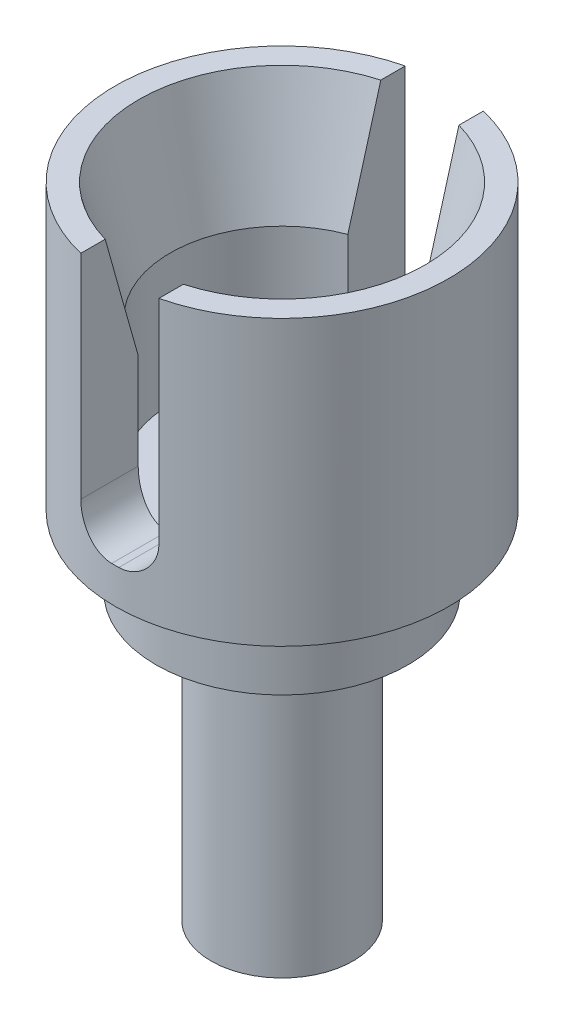
from build123d import *

# Parameters (mm, degrees)
SKETCH1_R               = 2
BOSS_EXTRUDE1_DEPTH     = 8
SKETCH1_3_R             = 3.55
BOSS_EXTRUDE2_DEPTH     = 2
SKETCH2_R               = 4.7
BOSS_EXTRUDE3_DEPTH     = 8
CUT_EXTRUDE1_DEPTH      = 20.188017094
CUT_EXTRUDE1_DEPTH_BACK = 7
SKETCH3_R               = 3.15
CHAMFER1_SIZE           = 3.3
CHAMFER1_SIZE2          = 0.884232335
CUT_EXTRUDE2_DEPTH      = 13.007497658
CUT_EXTRUDE2_DEPTH_BACK = 13.007497658
SKETCH4_W               = 2.2
SKETCH4_H               = 7
FILLET1_R               = 1


with BuildPart() as part:
    # Sketch1 → Boss-Extrude1 (new body)
    with BuildSketch(Plane(origin=(0, 0, 0), x_dir=(1, 0, 0), z_dir=(0, 1, 0))):
        Circle(SKETCH1_R)
    extrude(amount=-BOSS_EXTRUDE1_DEPTH)

    # Sketch1_3 → Boss-Extrude2 (add)
    with BuildSketch(Plane(origin=(0, 0, 0), x_dir=(1, 0, 0), z_dir=(0, 1, 0))):
        Circle(SKETCH1_3_R)
    extrude(amount=BOSS_EXTRUDE2_DEPTH)

    # Sketch2 → Boss-Extrude3 (add)
    with BuildSketch(Plane(origin=(0, 2, 0), x_dir=(1, 0, 0), z_dir=(0, 1, 0))):
        Circle(SKETCH2_R)
    extrude(amount=BOSS_EXTRUDE3_DEPTH)

    # Sketch3 → Cut-Extrude1 (cut, two sides: drawn at the far end of the back side and taken through both)
    with BuildSketch(Plane(origin=(0, 10, 0), x_dir=(1, 0, 0), z_dir=(0, 1, 0)).offset(-CUT_EXTRUDE1_DEPTH_BACK)):
        Circle(SKETCH3_R)
    extrude(amount=CUT_EXTRUDE1_DEPTH + CUT_EXTRUDE1_DEPTH_BACK, mode=Mode.SUBTRACT)

    # Chamfer1
    chamfer1_edges = [part.edges().sort_by_distance(p)[0] for p in [
        (-3.15, 10, 0),
    ]]
    chamfer1_side = [part.faces().sort_by_distance(p)[0] for p in [
        (-3.15, 6.5, 0),
    ]]
    chamfer(chamfer1_edges, length=CHAMFER1_SIZE, length2=CHAMFER1_SIZE2, reference=chamfer1_side[0])

    # Sketch4 → Cut-Extrude2 (cut, two sides: drawn at the far end of the back side and taken through both)
    with BuildSketch(Plane.XY.offset(-CUT_EXTRUDE2_DEPTH_BACK)):
        with Locations((0, 6.5)):
            Rectangle(SKETCH4_W, SKETCH4_H)
    extrude(amount=CUT_EXTRUDE2_DEPTH + CUT_EXTRUDE2_DEPTH_BACK, mode=Mode.SUBTRACT)

    # Fillet1
    fillet1_edges = [part.edges().sort_by_distance(p)[0] for p in [
        (1.1, 3, -3.760579146),
        (-1.1, 3, -3.760579146),
        (1.1, 3, 3.760579146),
        (-1.1, 3, 3.760579146),
    ]]
    fillet(fillet1_edges, radius=FILLET1_R)


solid = part.part
